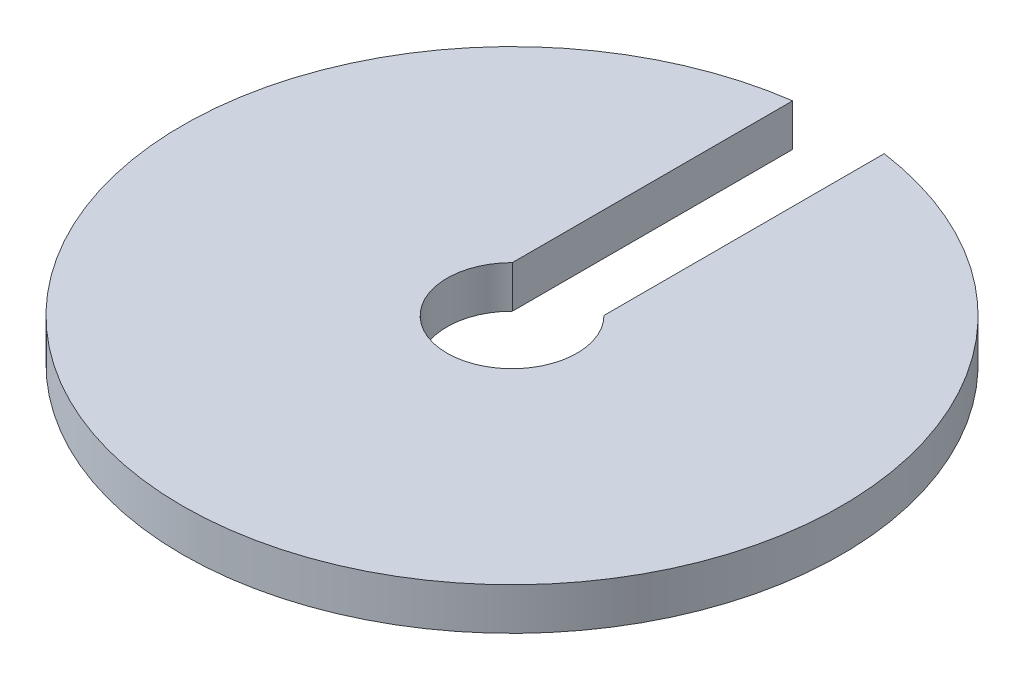
from build123d import *

# Parameters (mm, degrees)
SALIENTE_EXTRUIR1_DEPTH = 2.3


with BuildPart() as part:
    # Croquis1 → Saliente-Extruir1 (new body)
    with BuildSketch(Plane(origin=(0, 0, 0), x_dir=(1, 0, 0), z_dir=(0, 1, 0))):
        with BuildLine():
            Line((-2.5, 2.520416632), (-2.5, 17.82554347))
            ThreePointArc((-2.5, 17.82554347), (0, -18), (2.5, 17.82554347))
            Line((2.5, 17.82554347), (2.5, 2.520416632))
            ThreePointArc((2.5, 2.520416632), (0, -3.55), (-2.5, 2.520416632))
        make_face()
    extrude(amount=SALIENTE_EXTRUIR1_DEPTH)


solid = part.part
